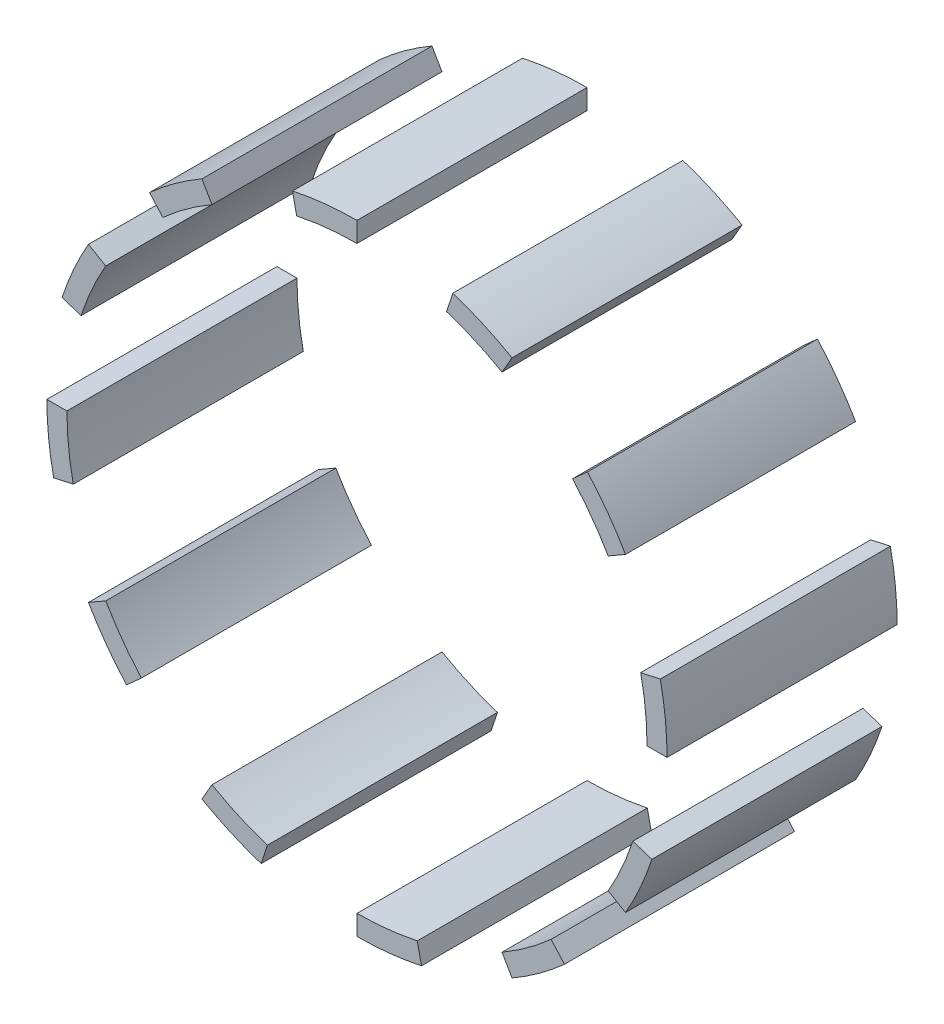
from build123d import *

# Parameters (mm, degrees)
BOSS_EXTRU_1_DEPTH    = 11.5
BOSS_EXTRU_1_2_DEPTH  = 11.5
BOSS_EXTRU_1_3_DEPTH  = 11.5
BOSS_EXTRU_1_4_DEPTH  = 11.5
BOSS_EXTRU_1_5_DEPTH  = 11.5
BOSS_EXTRU_1_6_DEPTH  = 11.5
BOSS_EXTRU_1_7_DEPTH  = 11.5
BOSS_EXTRU_1_8_DEPTH  = 11.5
BOSS_EXTRU_1_9_DEPTH  = 11.5
BOSS_EXTRU_1_10_DEPTH = 11.5
BOSS_EXTRU_1_11_DEPTH = 11.5
BOSS_EXTRU_1_12_DEPTH = 11.5


with BuildPart() as part:
    # Esquisse1 → Boss.-Extru.1 (new body)
    with BuildSketch(Plane.XY):
        with BuildLine():
            Line((14.5, 0), (15.5, 0))
            ThreePointArc((15.5, 0), (15.415089378, 1.620191181), (15.161287811, 3.222631208))
            Line((15.161287811, 3.222631208), (14.183140211, 3.014719517))
            ThreePointArc((14.183140211, 3.014719517), (14.420567483, 1.515662717), (14.5, 0))
        make_face()
    extrude(amount=BOSS_EXTRU_1_DEPTH)


with BuildPart() as body_2:
    # Esquisse1 → Boss.-Extru.1 2 (new body)
    with BuildSketch(Plane.XY):
        with BuildLine():
            Line((13.790319486, -4.480746418), (14.741376003, -4.789763413))
            ThreePointArc((14.741376003, -4.789763413), (14.159954593, -6.304417968), (13.423393759, -7.75))
            Line((13.423393759, -7.75), (12.557368355, -7.25))
            ThreePointArc((12.557368355, -7.25), (13.246409136, -5.897681325), (13.790319486, -4.480746418))
        make_face()
    extrude(amount=BOSS_EXTRU_1_2_DEPTH)


with BuildPart() as body_3:
    # Esquisse1 → Boss.-Extru.1 3 (new body)
    with BuildSketch(Plane.XY):
        with BuildLine():
            Line((9.702393792, -10.775599969), (10.371524399, -11.518744795))
            ThreePointArc((10.371524399, -11.518744795), (9.110671411, -12.539763413), (7.75, -13.423393759))
            Line((7.75, -13.423393759), (7.25, -12.557368355))
            ThreePointArc((7.25, -12.557368355), (8.522886158, -11.730746418), (9.702393792, -10.775599969))
        make_face()
    extrude(amount=BOSS_EXTRU_1_3_DEPTH)


with BuildPart() as body_4:
    # Esquisse1 → Boss.-Extru.1 4 (new body)
    with BuildSketch(Plane.XY):
        with BuildLine():
            Line((3.014719517, -14.183140211), (3.222631208, -15.161287811))
            ThreePointArc((3.222631208, -15.161287811), (1.620191181, -15.415089378), (0, -15.5))
            Line((0, -15.5), (0, -14.5))
            ThreePointArc((0, -14.5), (1.515662717, -14.420567483), (3.014719517, -14.183140211))
        make_face()
    extrude(amount=BOSS_EXTRU_1_4_DEPTH)


with BuildPart() as body_5:
    # Esquisse1 → Boss.-Extru.1 5 (new body)
    with BuildSketch(Plane.XY):
        with BuildLine():
            Line((-4.480746418, -13.790319486), (-4.789763413, -14.741376003))
            ThreePointArc((-4.789763413, -14.741376003), (-6.304417968, -14.159954593), (-7.75, -13.423393759))
            Line((-7.75, -13.423393759), (-7.25, -12.557368355))
            ThreePointArc((-7.25, -12.557368355), (-5.897681325, -13.246409136), (-4.480746418, -13.790319486))
        make_face()
    extrude(amount=BOSS_EXTRU_1_5_DEPTH)


with BuildPart() as body_6:
    # Esquisse1 → Boss.-Extru.1 6 (new body)
    with BuildSketch(Plane.XY):
        with BuildLine():
            Line((-10.775599969, -9.702393792), (-11.518744795, -10.371524399))
            ThreePointArc((-11.518744795, -10.371524399), (-12.539763413, -9.110671411), (-13.423393759, -7.75))
            Line((-13.423393759, -7.75), (-12.557368355, -7.25))
            ThreePointArc((-12.557368355, -7.25), (-11.730746418, -8.522886158), (-10.775599969, -9.702393792))
        make_face()
    extrude(amount=BOSS_EXTRU_1_6_DEPTH)


with BuildPart() as body_7:
    # Esquisse1 → Boss.-Extru.1 7 (new body)
    with BuildSketch(Plane.XY):
        with BuildLine():
            Line((-14.183140211, -3.014719517), (-15.161287811, -3.222631208))
            ThreePointArc((-15.161287811, -3.222631208), (-15.415089378, -1.620191181), (-15.5, 0))
            Line((-15.5, 0), (-14.5, 0))
            ThreePointArc((-14.5, 0), (-14.420567483, -1.515662717), (-14.183140211, -3.014719517))
        make_face()
    extrude(amount=BOSS_EXTRU_1_7_DEPTH)


with BuildPart() as body_8:
    # Esquisse1 → Boss.-Extru.1 8 (new body)
    with BuildSketch(Plane.XY):
        with BuildLine():
            Line((-13.790319486, 4.480746418), (-14.741376003, 4.789763413))
            ThreePointArc((-14.741376003, 4.789763413), (-14.159954593, 6.304417968), (-13.423393759, 7.75))
            Line((-13.423393759, 7.75), (-12.557368355, 7.25))
            ThreePointArc((-12.557368355, 7.25), (-13.246409136, 5.897681325), (-13.790319486, 4.480746418))
        make_face()
    extrude(amount=BOSS_EXTRU_1_8_DEPTH)


with BuildPart() as body_9:
    # Esquisse1 → Boss.-Extru.1 9 (new body)
    with BuildSketch(Plane.XY):
        with BuildLine():
            Line((-9.702393792, 10.775599969), (-10.371524399, 11.518744795))
            ThreePointArc((-10.371524399, 11.518744795), (-9.110671411, 12.539763413), (-7.75, 13.423393759))
            Line((-7.75, 13.423393759), (-7.25, 12.557368355))
            ThreePointArc((-7.25, 12.557368355), (-8.522886158, 11.730746418), (-9.702393792, 10.775599969))
        make_face()
    extrude(amount=BOSS_EXTRU_1_9_DEPTH)


with BuildPart() as body_10:
    # Esquisse1 → Boss.-Extru.1 10 (new body)
    with BuildSketch(Plane.XY):
        with BuildLine():
            Line((-3.014719517, 14.183140211), (-3.222631208, 15.161287811))
            ThreePointArc((-3.222631208, 15.161287811), (-1.620191181, 15.415089378), (0, 15.5))
            Line((0, 15.5), (0, 14.5))
            ThreePointArc((0, 14.5), (-1.515662717, 14.420567483), (-3.014719517, 14.183140211))
        make_face()
    extrude(amount=BOSS_EXTRU_1_10_DEPTH)


with BuildPart() as body_11:
    # Esquisse1 → Boss.-Extru.1 11 (new body)
    with BuildSketch(Plane.XY):
        with BuildLine():
            Line((4.480746418, 13.790319486), (4.789763413, 14.741376003))
            ThreePointArc((4.789763413, 14.741376003), (6.304417968, 14.159954593), (7.75, 13.423393759))
            Line((7.75, 13.423393759), (7.25, 12.557368355))
            ThreePointArc((7.25, 12.557368355), (5.897681325, 13.246409136), (4.480746418, 13.790319486))
        make_face()
    extrude(amount=BOSS_EXTRU_1_11_DEPTH)


with BuildPart() as body_12:
    # Esquisse1 → Boss.-Extru.1 12 (new body)
    with BuildSketch(Plane.XY):
        with BuildLine():
            Line((10.775599969, 9.702393792), (11.518744795, 10.371524399))
            ThreePointArc((11.518744795, 10.371524399), (12.539763413, 9.110671411), (13.423393759, 7.75))
            Line((13.423393759, 7.75), (12.557368355, 7.25))
            ThreePointArc((12.557368355, 7.25), (11.730746418, 8.522886158), (10.775599969, 9.702393792))
        make_face()
    extrude(amount=BOSS_EXTRU_1_12_DEPTH)


solid = Compound([part.part, body_2.part, body_3.part, body_4.part, body_5.part, body_6.part, body_7.part, body_8.part, body_9.part, body_10.part, body_11.part, body_12.part])
